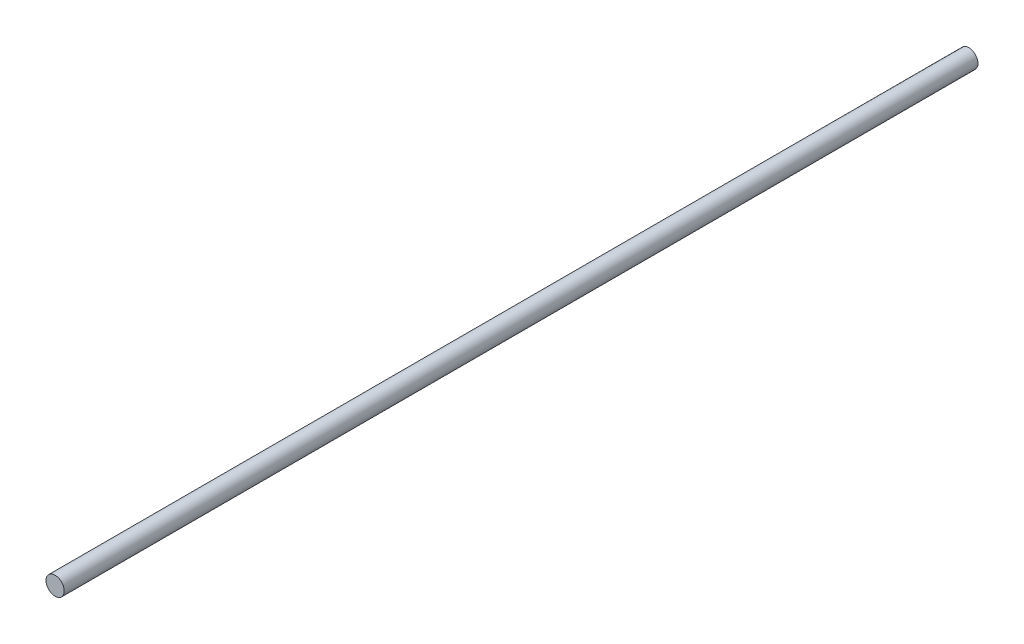
from build123d import *

# Parameters (mm, degrees)
SKETCH_1_R      = 2
EXTRUDE_1_DEPTH = 200


with BuildPart() as part:
    # 草图1 → 凸台-拉伸1 (new body)
    with BuildSketch(Plane.XY):
        Circle(SKETCH_1_R)
    extrude(amount=EXTRUDE_1_DEPTH)


solid = part.part
